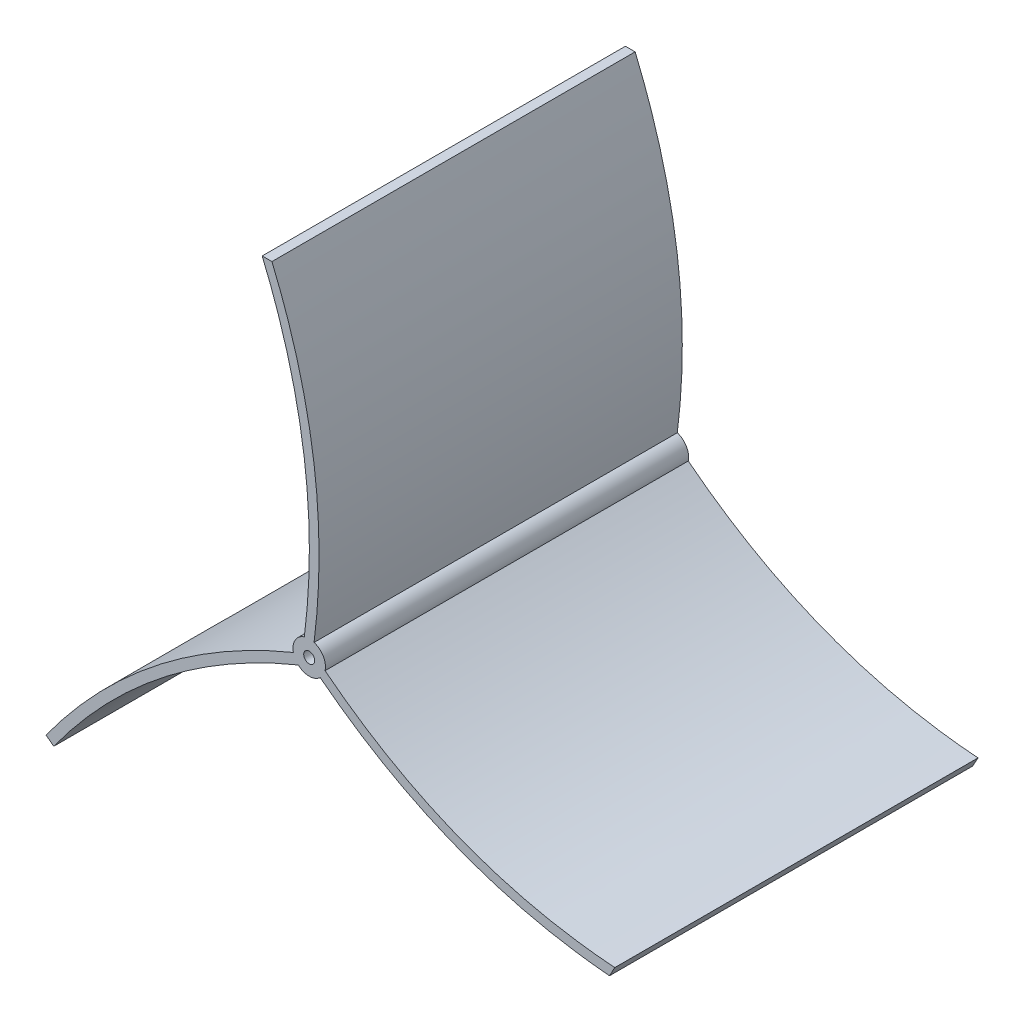
from build123d import *

# Parameters (mm, degrees)
SKETCH_1_R      = 1.7
EXTRUDE_1_DEPTH = 112


with BuildPart() as part:
    # 草图1 → 凸台-拉伸1 (new body)
    with BuildSketch(Plane.XY):
        with BuildLine():
            Line((-14.240871753, 100.966248357), (-11.240871753, 100.966248357))
            add(Edge.make_bspline(
                [(1.759128247, 5.747194997), (8.029571787, 55.068895095), (-11.240871753, 100.966248357)],
                knots=[0, 0, 0, 1, 1, 1], degree=2))
            ThreePointArc((1.759128247, 5.747194997), (4.589255266, 3.47749899), (5.139806158, -0.108310908))
            add(Edge.make_bspline(
                [(5.139806158, -0.108310908), (44.496199832, -31.024270121), (94.481890105, -34.717837588)],
                knots=[0, 0, 0, 1, 1, 1], degree=2))
            Line((94.481890105, -34.717837588), (92.849882086, -37.717837588))
            add(Edge.make_bspline(
                [(3.639806158, -2.706387119), (43.024769755, -33.414304879), (92.849882086, -37.717837588)],
                knots=[0, 0, 0, 1, 1, 1], degree=2))
            ThreePointArc((3.639806158, -2.706387119), (0.259128247, -4.02250101), (-3.121549663, -2.706387119))
            add(Edge.make_bspline(
                [(-3.121549663, -2.706387119), (-49.234666098, -21.664678742), (-78.501197374, -62.111237788)],
                knots=[0, 0, 0, 1, 1, 1], degree=2))
            Line((-78.501197374, -62.111237788), (-80.904697275, -60.315913799))
            add(Edge.make_bspline(
                [(-4.621549663, -0.108310908), (-51.223666378, -19.399256747), (-80.904697275, -60.315913799)],
                knots=[0, 0, 0, 1, 1, 1], degree=2))
            ThreePointArc((-4.621549663, -0.108310908), (-4.070998772, 3.47749899), (-1.240871753, 5.747194997))
            add(Edge.make_bspline(
                [(-1.240871753, 5.747194997), (5.029571787, 55.068895095), (-14.240871753, 100.966248357)],
                knots=[0, 0, 0, 1, 1, 1], degree=2))
        make_face()
        with Locations((0.259128247, 0.97749899)):
            Circle(SKETCH_1_R, mode=Mode.SUBTRACT)
    extrude(amount=EXTRUDE_1_DEPTH)


solid = part.part
